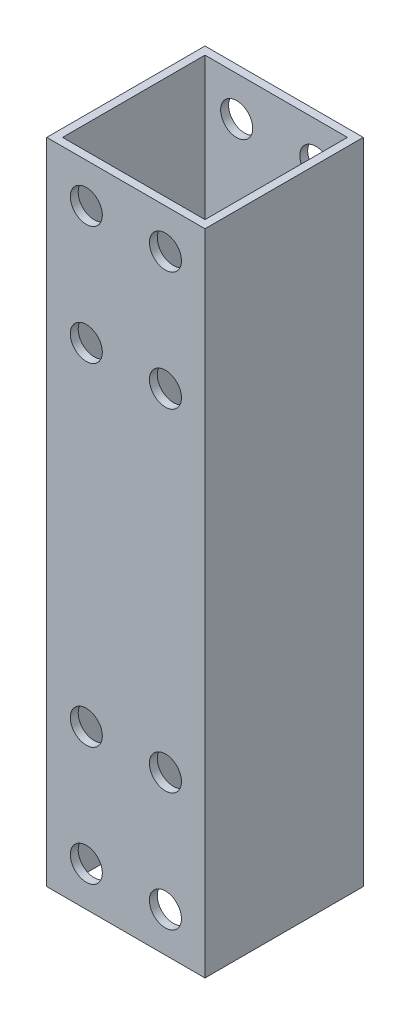
from build123d import *

# Parameters (mm, degrees)
SKETCH_1_W          = 20
SKETCH_1_H          = 20
SKETCH_1_W_2        = 18
SKETCH_1_H_2        = 18
EXTRUDE_1_DEPTH     = 82
SKETCH_2_R          = 2.025
CUT_EXTRUDE_1_DEPTH = 21


with BuildPart() as part:
    # 草图1 → 凸台-拉伸1 (new body)
    with BuildSketch(Plane(origin=(0, 0, 0), x_dir=(1, 0, 0), z_dir=(0, 1, 0))):
        Rectangle(SKETCH_1_W, SKETCH_1_H)
        Rectangle(SKETCH_1_W_2, SKETCH_1_H_2, mode=Mode.SUBTRACT)
    extrude(amount=EXTRUDE_1_DEPTH)

    # 草图2 → 切除-拉伸1 (cut, through all)
    with BuildSketch(Plane.XY.offset(10)):
        with Locations((-5, 5)):
            Circle(SKETCH_2_R)
        with Locations((-5, 20)):
            Circle(SKETCH_2_R)
        with Locations((5, 20)):
            Circle(SKETCH_2_R)
        with Locations((5, 5)):
            Circle(SKETCH_2_R)
        with Locations((5, 77)):
            Circle(SKETCH_2_R)
        with Locations((-5, 77)):
            Circle(SKETCH_2_R)
        with Locations((-5, 62)):
            Circle(SKETCH_2_R)
        with Locations((5, 62)):
            Circle(SKETCH_2_R)
    extrude(amount=-CUT_EXTRUDE_1_DEPTH, mode=Mode.SUBTRACT)


solid = part.part
